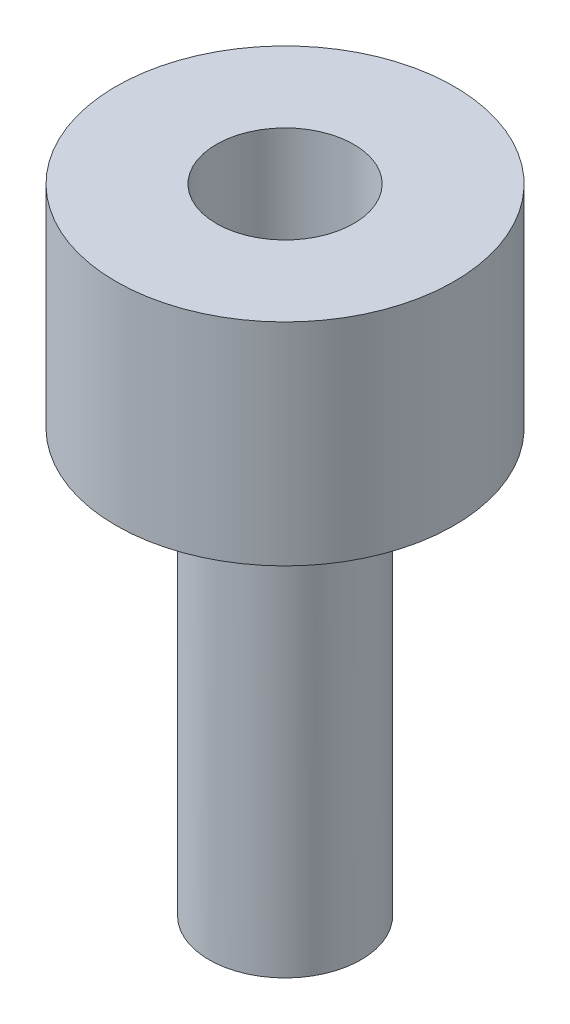
from build123d import *

# Parameters (mm, degrees)
SKETCH1_R           = 3.6
BOSS_EXTRUDE1_DEPTH = 10
SKETCH2_R           = 8
BOSS_EXTRUDE2_DEPTH = 10
SKETCH3_R           = 3.25
CUT_EXTRUDE1_DEPTH  = 8
BOSS_EXTRUDE3_START = 10
SKETCH4_R           = 3.6
BOSS_EXTRUDE3_DEPTH = 10
FILLET1_R           = 2


with BuildPart() as part:
    # Sketch1 → Boss-Extrude1 (new body)
    with BuildSketch(Plane(origin=(0, 0, 0), x_dir=(1, 0, 0), z_dir=(0, 1, 0))):
        with Locations(Location((0, 0, 0), (0, 0, 270))):
            Circle(SKETCH1_R)
    extrude(amount=BOSS_EXTRUDE1_DEPTH)

    # Sketch2 → Boss-Extrude2 (add)
    with BuildSketch(Plane(origin=(0, 10, 0), x_dir=(1, 0, 0), z_dir=(0, 1, 0))):
        with Locations(Location((0, 0, 0), (0, 0, 270))):
            Circle(SKETCH2_R)
    extrude(amount=BOSS_EXTRUDE2_DEPTH)

    # Sketch3 → Cut-Extrude1 (cut)
    with BuildSketch(Plane(origin=(0, 20, 0), x_dir=(1, 0, 0), z_dir=(0, 1, 0))):
        with Locations(Location((0, 0, 0), (0, 0, 270))):
            Circle(SKETCH3_R)
    extrude(amount=-CUT_EXTRUDE1_DEPTH, mode=Mode.SUBTRACT)

    # Sketch4 → Boss-Extrude3 (add)
    with BuildSketch(Plane.XZ.offset(BOSS_EXTRUDE3_START)):
        with Locations(Location((0, 0, 0), (0, 0, 270))):
            Circle(SKETCH4_R)
    extrude(amount=-BOSS_EXTRUDE3_DEPTH)

    # Fillet1
    fillet1_edges = [part.edges().sort_by_distance(p)[0] for p in [
        (0, 10, -3.6),
    ]]
    fillet(fillet1_edges, radius=FILLET1_R)


solid = part.part
